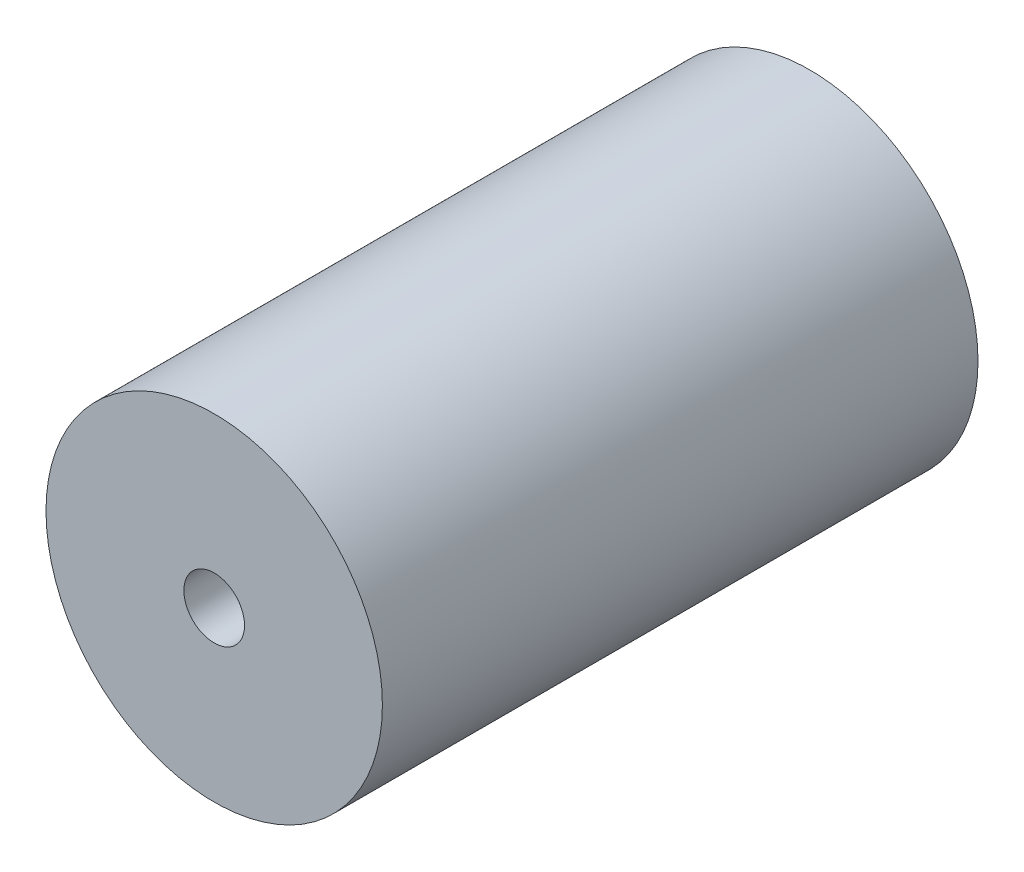
from build123d import *

# Parameters (mm, degrees)
SKETCH1_R           = 30.5
BOSS_EXTRUDE1_DEPTH = 108
SKETCH2_R           = 5.5
CUT_EXTRUDE1_DEPTH  = 110


with BuildPart() as part:
    # Sketch1 → Boss-Extrude1 (new body)
    with BuildSketch(Plane.XY):
        Circle(SKETCH1_R)
    extrude(amount=BOSS_EXTRUDE1_DEPTH)

    # Sketch2 → Cut-Extrude1 (cut)
    with BuildSketch(Plane.XY):
        Circle(SKETCH2_R)
    extrude(amount=CUT_EXTRUDE1_DEPTH, mode=Mode.SUBTRACT)


solid = part.part
